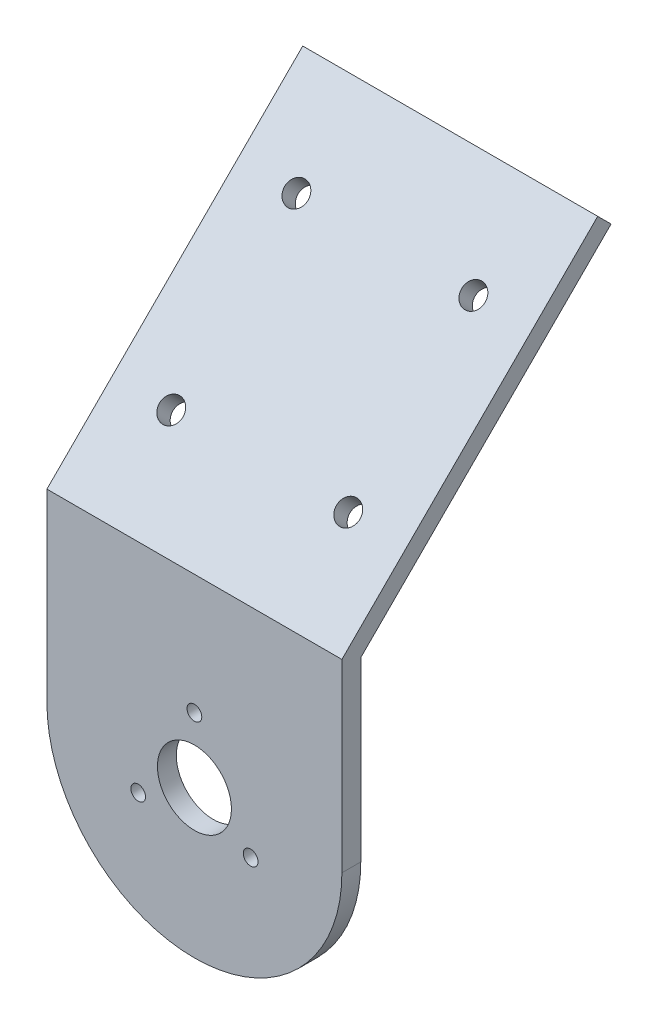
from build123d import *

# Parameters (mm, degrees)
SKETCH1_R           = 6.273243026
SKETCH1_R_2         = 1.25
BOSS_EXTRUDE1_DEPTH = 3.2
BOSS_EXTRUDE2_DEPTH = 50
CUT_EXTRUDE1_REACH  = 74.091
SKETCH3_R           = 2


with BuildPart() as part:
    # Sketch1 → Boss-Extrude1 (new body)
    with BuildSketch(Plane.XY):
        with BuildLine():
            Line((-25, 0), (-25, 30))
            Line((-25, 30), (25, 30))
            Line((25, 30), (25, 0))
            ThreePointArc((25, 0), (0, -25), (-25, 0))
        make_face()
        Circle(SKETCH1_R, mode=Mode.SUBTRACT)
        with Locations((0, 11)):
            Circle(SKETCH1_R_2, mode=Mode.SUBTRACT)
        with Locations((9.526279442, -5.5)):
            Circle(SKETCH1_R_2, mode=Mode.SUBTRACT)
        with Locations((-9.526279442, -5.5)):
            Circle(SKETCH1_R_2, mode=Mode.SUBTRACT)
    extrude(amount=BOSS_EXTRUDE1_DEPTH)

    # Sketch2 → Boss-Extrude2 (add)
    with BuildSketch(Plane(origin=(25, 0, 0), x_dir=(0, 0, -1), z_dir=(1, 0, 0))):
        Polygon((0, 30), (42.426406871, 72.426406871), (40.163665171, 74.689148571), (-3.2, 31.3254834), (-3.2, 30), align=None)
    extrude(amount=-BOSS_EXTRUDE2_DEPTH)

    # Sketch3 → Cut-Extrude1 (cut, up to next)
    with BuildSketch(Plane(origin=(0, 17.2627417, 17.2627417), x_dir=(1, 0, 0), z_dir=(0, 0.707106781, 0.707106781)), mode=Mode.PRIVATE) as cut_extrude1_sk1:
        with Locations((15, 65.550461736)):
            Circle(SKETCH3_R)
    cut_extrude1_tool1 = extrude(cut_extrude1_sk1.sketch, amount=-CUT_EXTRUDE1_REACH, mode=Mode.PRIVATE) & part.part
    add(cut_extrude1_tool1.solids().sort_by_distance((15, 63.613918, -29.088434))[0], mode=Mode.SUBTRACT)
    # Sketch3 → Cut-Extrude1 (cut, up to next)
    with BuildSketch(Plane(origin=(0, 17.2627417, 17.2627417), x_dir=(1, 0, 0), z_dir=(0, 0.707106781, 0.707106781)), mode=Mode.PRIVATE) as cut_extrude1_sk2:
        with Locations((15, 35.550461736)):
            Circle(SKETCH3_R)
    cut_extrude1_tool2 = extrude(cut_extrude1_sk2.sketch, amount=-CUT_EXTRUDE1_REACH, mode=Mode.PRIVATE) & part.part
    add(cut_extrude1_tool2.solids().sort_by_distance((15, 42.400714, -7.875231))[0], mode=Mode.SUBTRACT)
    # Sketch3 → Cut-Extrude1 (cut, up to next)
    with BuildSketch(Plane(origin=(0, 17.2627417, 17.2627417), x_dir=(1, 0, 0), z_dir=(0, 0.707106781, 0.707106781)), mode=Mode.PRIVATE) as cut_extrude1_sk3:
        with Locations((-15, 65.550461736)):
            Circle(SKETCH3_R)
    cut_extrude1_tool3 = extrude(cut_extrude1_sk3.sketch, amount=-CUT_EXTRUDE1_REACH, mode=Mode.PRIVATE) & part.part
    add(cut_extrude1_tool3.solids().sort_by_distance((-15, 63.613918, -29.088434))[0], mode=Mode.SUBTRACT)
    # Sketch3 → Cut-Extrude1 (cut, up to next)
    with BuildSketch(Plane(origin=(0, 17.2627417, 17.2627417), x_dir=(1, 0, 0), z_dir=(0, 0.707106781, 0.707106781)), mode=Mode.PRIVATE) as cut_extrude1_sk4:
        with Locations((-15, 35.550461736)):
            Circle(SKETCH3_R)
    cut_extrude1_tool4 = extrude(cut_extrude1_sk4.sketch, amount=-CUT_EXTRUDE1_REACH, mode=Mode.PRIVATE) & part.part
    add(cut_extrude1_tool4.solids().sort_by_distance((-15, 42.400714, -7.875231))[0], mode=Mode.SUBTRACT)


solid = part.part
